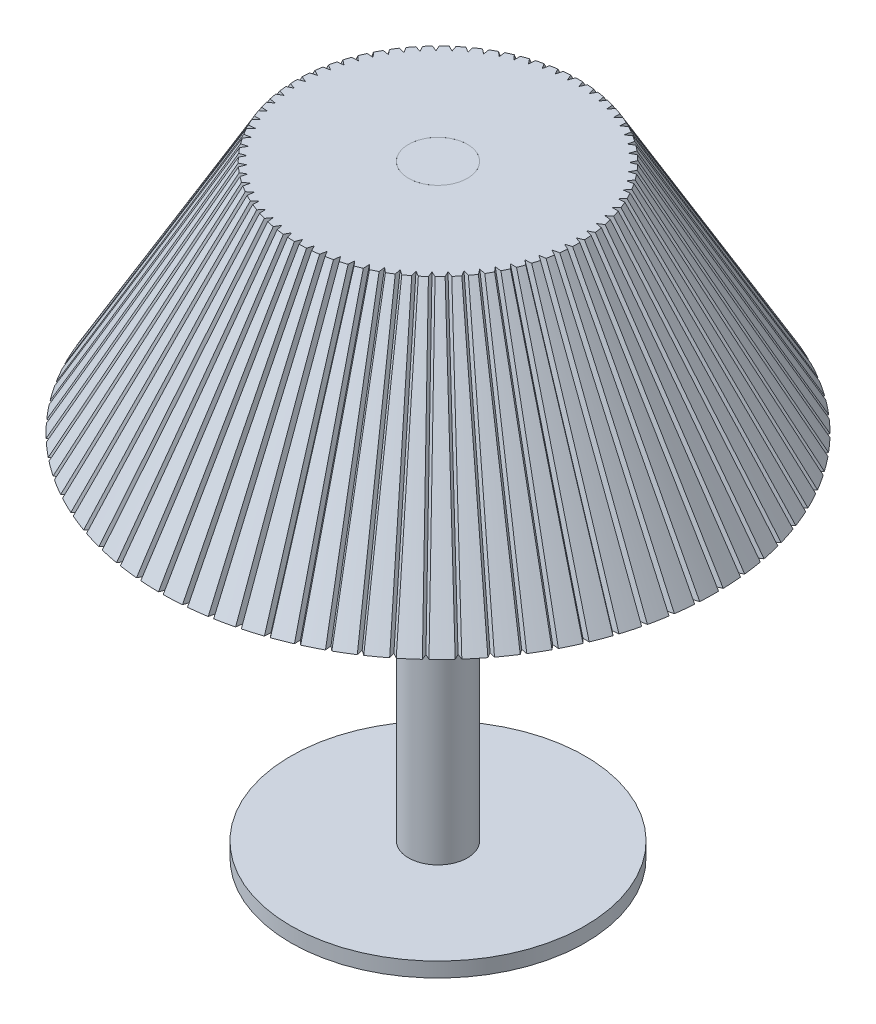
from build123d import *

# Parameters (mm, degrees)
SKETCH1_R           = 25
BOSS_EXTRUDE1_DEPTH = 2.5
SKETCH2_R           = 5
BOSS_EXTRUDE2_DEPTH = 100
CIRPATTERN1_COUNT   = 75


with BuildPart() as part:
    # Sketch1 → Boss-Extrude1 (new body)
    with BuildSketch(Plane(origin=(0, 0, 0), x_dir=(1, 0, 0), z_dir=(0, 1, 0))):
        Circle(SKETCH1_R)
    extrude(amount=BOSS_EXTRUDE1_DEPTH)

    # Sketch2 → Boss-Extrude2 (add)
    with BuildSketch(Plane(origin=(0, 2.5, 0), x_dir=(1, 0, 0), z_dir=(0, 1, 0))):
        Circle(SKETCH2_R)
    extrude(amount=BOSS_EXTRUDE2_DEPTH)


with BuildPart() as body_2:
    # Sketch3 → Revolve1 (revolve)
    with BuildSketch(Plane.XY):
        Polygon((20, 102.5), (24, 102.5), (47.094010768, 62.5), (42.516660498, 62.5), (20, 101.5), (5, 101.5), (5, 102.5), align=None)
    revolve(axis=Axis((0, -5.125, 0), (0, 1, 0)))

    # Cut-Sweep2: sweep along a path in Sketch4
    with BuildLine(Plane(origin=(0, 36.017304845, 62.383801944), x_dir=(1, 0, 0), z_dir=(0, 0.5, 0.866025404))) as cut_sweep2_path:
        Line((0, 30.579582353), (0, 76.767603888))
    # Sketch9 → Cut-Sweep2 (sweep, cut)
    with BuildSketch(Plane(origin=(0, 102.5, 0), x_dir=(1, 0, 0), z_dir=(0, 1, 0))):
        Polygon((0, -23), (-1, -25.5), (1, -25.5), align=None)
    cut_sweep2 = sweep(path=cut_sweep2_path.line, mode=Mode.SUBTRACT)

    # CirPattern1: Cut-Sweep2 ×75 about axis
    cirpattern1_axis = Axis((0, 0, 0), (0, 1, 0))
    for i in range(1, CIRPATTERN1_COUNT):
        add(cut_sweep2.rotate(cirpattern1_axis, i * 360 / CIRPATTERN1_COUNT), mode=Mode.SUBTRACT)


solid = Compound([part.part, body_2.part])
